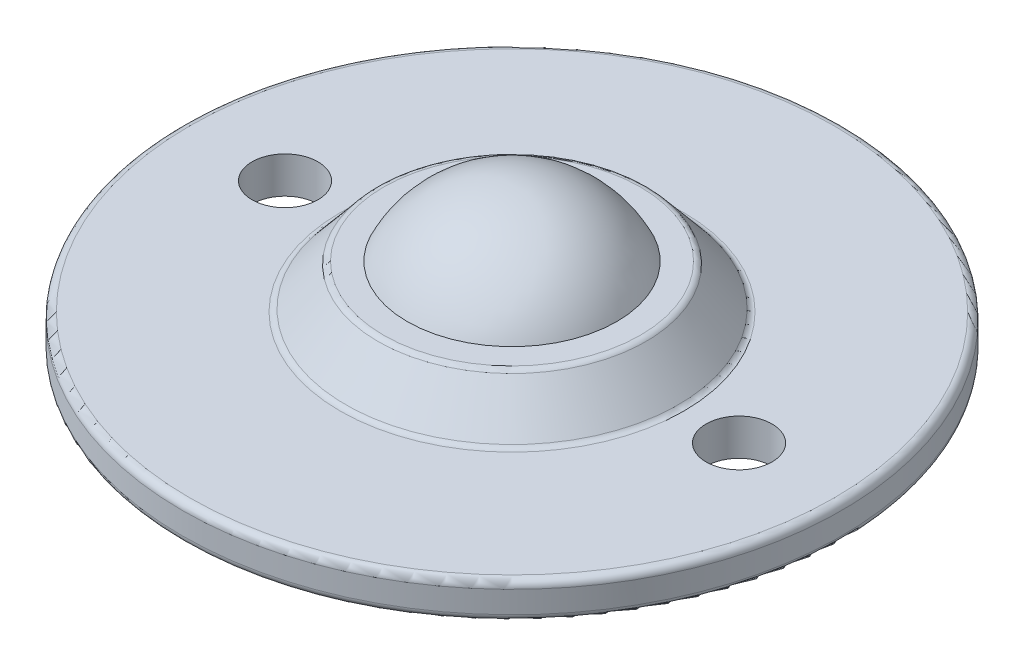
from build123d import *

# Parameters (mm, degrees)
SKETCH3_R          = 2.25
CUT_EXTRUDE1_DEPTH = 12.5
FILLET1_R          = 0.5


with BuildPart() as part:
    # Sketch2 → Revolve1 (revolve)
    with BuildSketch(Plane(origin=(0, 0, 0), x_dir=(0, 0, -1), z_dir=(1, 0, 0))):
        with BuildLine():
            Line((0, 7.9375), (0, -11.0625))
            ThreePointArc((0, -11.0625), (6.296885391, -9.09550112), (10.3545, -3.894))
            ThreePointArc((10.3545, -3.894), (11.39119124, -2.565054014), (13, -2.0625))
            Line((13, -2.0625), (22.5, -2.0625))
            Line((22.5, -2.0625), (22.5, 0.4375))
            Line((22.5, 0.4375), (11.5, 0.4375))
            Line((11.5, 0.4375), (9, 3.4375))
            Line((9, 3.4375), (7.154544011, 3.4375))
            ThreePointArc((7.154544011, 3.4375), (4.226035376, 6.71896802), (0, 7.9375))
        make_face()
    revolve(axis=Axis((0, 7.9375, 0), (0, -1, 0)))

    # Sketch3 → Cut-Extrude1 (cut, through all)
    with BuildSketch(Plane(origin=(0, 0.4375, 0), x_dir=(1, 0, 0), z_dir=(0, 1, 0))):
        with Locations((-15.5, 0)):
            Circle(SKETCH3_R)
        with Locations((15.5, 0)):
            Circle(SKETCH3_R)
    extrude(amount=-CUT_EXTRUDE1_DEPTH, mode=Mode.SUBTRACT)

    # Fillet1
    fillet1_edges = [part.edges().sort_by_distance(p)[0] for p in [
        (0, 0.4375, 11.5),
        (0, 3.4375, 9),
        (0, -2.0625, 22.5),
        (0, 0.4375, 22.5),
    ]]
    fillet(fillet1_edges, radius=FILLET1_R)


solid = part.part
